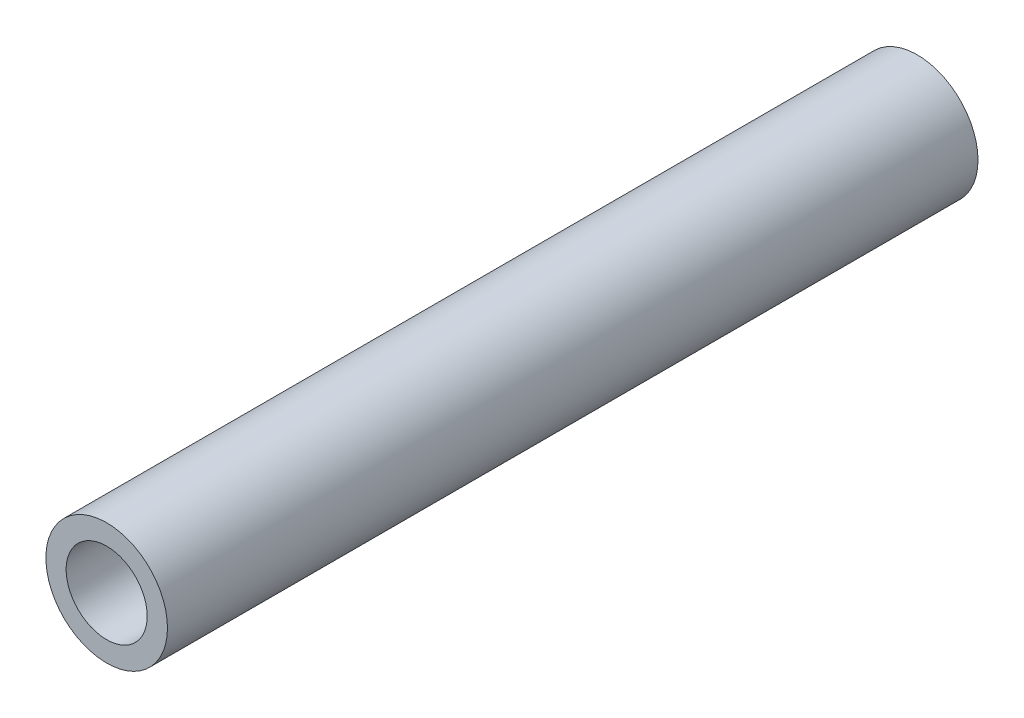
from build123d import *

# Parameters (mm, degrees)
SKETCH1_R           = 7.62
SKETCH1_R_2         = 5.08
BOSS_EXTRUDE1_DEPTH = 101.6


with BuildPart() as part:
    # Sketch1 → Boss-Extrude1 (new body)
    with BuildSketch(Plane.XY):
        Circle(SKETCH1_R)
        Circle(SKETCH1_R_2, mode=Mode.SUBTRACT)
    extrude(amount=BOSS_EXTRUDE1_DEPTH)


solid = part.part
